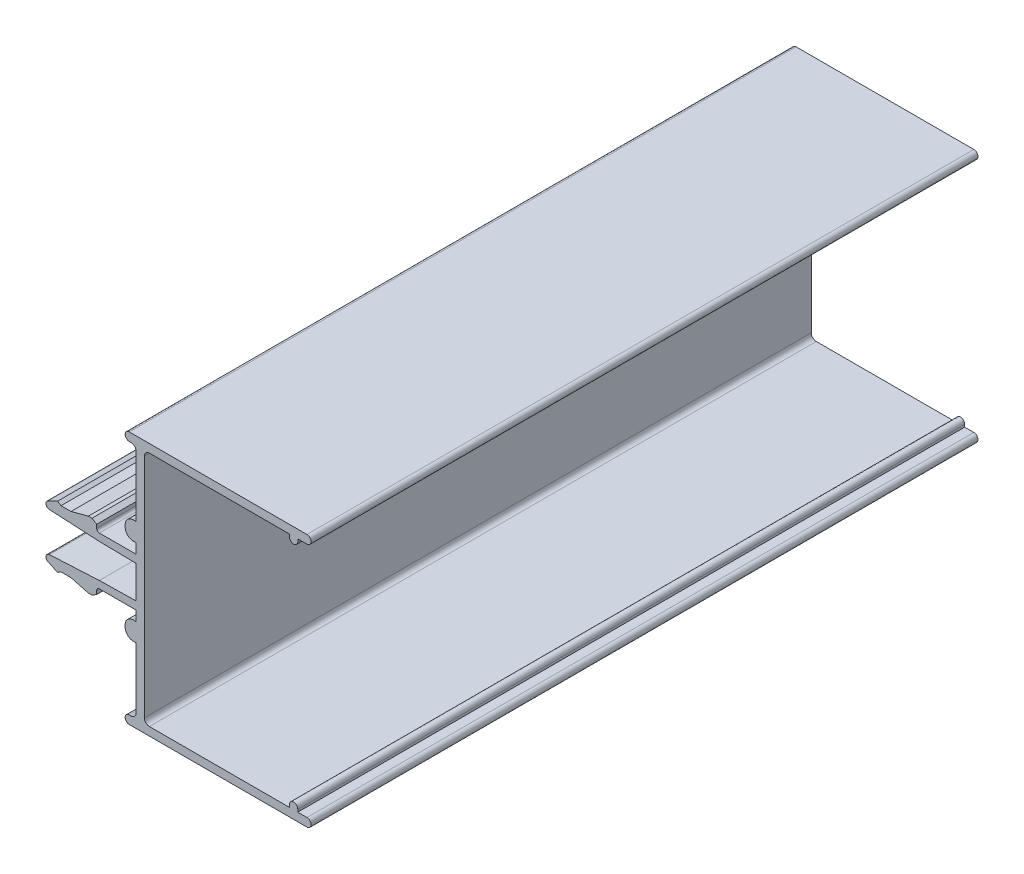
from build123d import *

# Parameters (mm, degrees)
MAIN_EXTRUSION_DEPTH = 100


with BuildPart() as part:
    # Sk Main Extrusion → Main Extrusion (new body)
    with BuildSketch(Plane.XY):
        with BuildLine():
            Line((-3.83, 2.5328), (-11.31249103, 2.925083334))
            ThreePointArc((-11.31249103, 2.925083334), (-11.819967595, 3.366238681), (-11.514691833, 3.965369062))
            Line((-11.514691833, 3.965369062), (-10.100108722, 4.625))
            Line((-10.100108722, 4.625), (-9.58, 4.3))
            Line((-9.58, 4.3), (-8.08, 4.3))
            Line((-8.08, 4.3), (-5.474147193, 5))
            Line((-5.474147193, 5), (-4.934147193, 5))
            Line((-4.934147193, 5), (-4.23, 4.56))
            Line((-4.23, 4.56), (-4.23, 4.025))
            ThreePointArc((-4.23, 4.025), (-4.112842694, 3.742157269), (-3.829999948, 3.625))
            Line((-3.829999948, 3.625), (1.67, 3.625))
            Line((1.67, 3.625), (1.67, 5.120055168))
            Line((1.67, 5.120055168), (1.19886836, 5.120055168))
            ThreePointArc((1.19886836, 5.120055168), (0.3740485, 5.504367154), (0.038, 6.35))
            Line((0.038, 6.35), (0.038, 6.65))
            ThreePointArc((0.038, 6.65), (0.3740485, 7.495632846), (1.19886836, 7.879944832))
            Line((1.19886836, 7.879944832), (1.67, 7.879944832))
            Line((1.67, 7.879944832), (1.67, 17))
            ThreePointArc((1.67, 17), (1.450330086, 17.530330086), (0.92, 17.75))
            Line((0.92, 17.75), (0.663, 17.75))
            ThreePointArc((0.663, 17.75), (0.038, 18.375), (0.663, 19))
            Line((0.663, 19), (27.295, 19))
            ThreePointArc((27.295, 19), (27.92, 18.375), (27.295, 17.75))
            Line((27.295, 17.75), (25.92, 17.75))
            Line((25.92, 17.75), (25.92, 17.375))
            ThreePointArc((25.92, 17.375), (25.295, 16.75), (24.67, 17.375))
            Line((24.67, 17.375), (24.67, 17.75))
            Line((24.67, 17.75), (3.67, 17.75))
            ThreePointArc((3.67, 17.75), (3.139669914, 17.530330086), (2.92, 17))
            Line((2.92, 17), (2.92, -17))
            ThreePointArc((2.92, -17), (3.139669914, -17.530330086), (3.67, -17.75))
            Line((3.67, -17.75), (24.67, -17.75))
            Line((24.67, -17.75), (24.67, -17.375))
            ThreePointArc((24.67, -17.375), (25.295, -16.75), (25.92, -17.375))
            Line((25.92, -17.375), (25.92, -17.75))
            Line((25.92, -17.75), (27.295, -17.75))
            ThreePointArc((27.295, -17.75), (27.92, -18.375), (27.295, -19))
            Line((27.295, -19), (0.663, -19))
            ThreePointArc((0.663, -19), (0.038, -18.375), (0.663, -17.75))
            Line((0.663, -17.75), (0.92, -17.75))
            ThreePointArc((0.92, -17.75), (1.450330086, -17.530330086), (1.67, -17))
            Line((1.67, -17), (1.67, -7.879944832))
            Line((1.67, -7.879944832), (1.19886836, -7.879944832))
            ThreePointArc((1.19886836, -7.879944832), (0.374048509, -7.495632855), (0.038, -6.650000026))
            Line((0.038, -6.650000026), (0.038, -6.350000026))
            ThreePointArc((0.038, -6.350000026), (0.374048491, -5.504367164), (1.19886836, -5.120055168))
            Line((1.19886836, -5.120055168), (1.67, -5.120055168))
            Line((1.67, -5.120055168), (1.67, -3.625))
            Line((1.67, -3.625), (-3.829999948, -3.625))
            ThreePointArc((-3.829999948, -3.625), (-4.112842694, -3.742157269), (-4.23, -4.025))
            Line((-4.23, -4.025), (-4.23, -4.56))
            Line((-4.23, -4.56), (-4.934147193, -5))
            Line((-4.934147193, -5), (-5.474147193, -5))
            Line((-5.474147193, -5), (-8.08, -4.3))
            Line((-8.08, -4.3), (-9.58, -4.3))
            Line((-9.58, -4.3), (-10.100108722, -4.625))
            Line((-10.100108722, -4.625), (-11.514691833, -3.965369062))
            ThreePointArc((-11.514691833, -3.965369062), (-11.819967595, -3.366238681), (-11.31249103, -2.925083334))
            Line((-11.31249103, -2.925083334), (-3.83, -2.5328))
            Line((-3.83, -2.5328), (1.67, -2.436797143))
            Line((1.67, -2.436797143), (1.67, 2.436797143))
            Line((1.67, 2.436797143), (-3.83, 2.5328))
        make_face()
    extrude(amount=-MAIN_EXTRUSION_DEPTH)


solid = part.part
